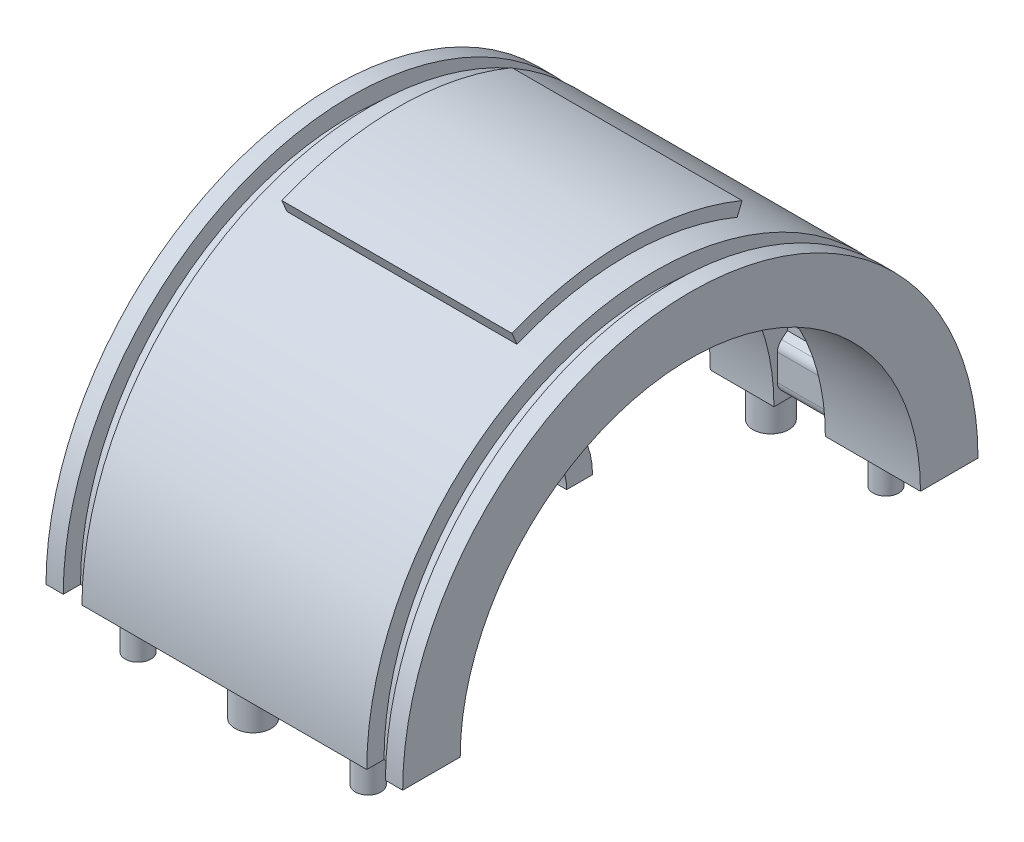
from build123d import *

# Parameters (mm, degrees)
REVOLVE1_ANGLE       = 180
BOSS_EXTRUDE1_DEPTH  = 31
CUT_EXTRUDE1_DEPTH   = 100
CIRPATTERN1_COUNT    = 6
SKETCH5_R            = 3.1275
SKETCH5_R_2          = 2.2275
BOSS_EXTRUDE2_DEPTH  = 7.155
CUT_EXTRUDE2_DEPTH   = 4.46775
MIRROR3_COPY_1_DEPTH = 4.46775
CHAMFER1_SIZE        = 2.5
FILLET1_R            = 2
FILLET2_R            = 2
SKETCH9_W            = 40
SKETCH9_H            = 2.250900446
REVOLVE2_ANGLE       = 45


with BuildPart() as part:
    # Sketch1 → Revolve1 (revolve)
    with BuildSketch(Plane(origin=(0, 0, 0), x_dir=(1, 0, 0), z_dir=(0, 1, 0))):
        with BuildLine():
            Line((24.75, 47), (28, 47))
            Line((28, 47), (28, 50))
            Line((28, 50), (31, 50))
            Line((31, 50), (31, 40))
            Line((31, 40), (-26, 40))
            add(Edge.make_bspline(
                [(-26, 40), (-27.013739482, 36.809226409), (-29.345099443, 27.828113636), (-24.523456801, 15.394699457), (-15.526264119, 14.868541835), (-9.946885113, 14)],
                knots=[0, 0, 0, 0, 0.285238859, 0.456571244, 0.779817638, 0.779817638, 0.779817638, 0.779817638], degree=3))
            Line((-9.946885113, 14), (-10, 9.5))
            add(Edge.make_bspline(
                [(-31, 40), (-32.939614555, 37.540591148), (-36.933922801, 27.582274875), (-30.082407751, 11.775662378), (-17.92187093, 9.5), (-10, 9.5)],
                knots=[0, 0, 0, 0, 0.268184782, 0.444494999, 0.822560414, 0.822560414, 0.822560414, 0.822560414], degree=3))
            Line((-31, 40), (-31, 50))
            Line((-31, 50), (-28, 50))
            Line((-28, 50), (-28, 47))
            Line((-28, 47), (-24.75, 47))
            Line((-24.75, 47), (-24.75, 50))
            Line((-24.75, 50), (24.75, 50))
            Line((24.75, 50), (24.75, 47))
        make_face()
    revolve(axis=Axis((0, 0, 0), (1, 0, 0)), revolution_arc=REVOLVE1_ANGLE)

    # Sketch6 → Boss-Extrude1 (add)
    with BuildSketch(Plane(origin=(0, 0, 0), x_dir=(0, 0, -1), z_dir=(1, 0, 0))):
        with BuildLine():
            Line((-14, 0), (-9.5, 0))
            ThreePointArc((-9.5, 0), (0, 9.5), (9.5, 0))
            Line((9.5, 0), (14, 0))
            ThreePointArc((14, 0), (0, 14), (-14, 0))
        make_face()
    extrude(amount=-BOSS_EXTRUDE1_DEPTH)

    # Sketch7 → Cut-Extrude1 (cut)
    with BuildSketch(Plane(origin=(31, 0, 0), x_dir=(0, 0, -1), z_dir=(1, 0, 0))):
        with BuildLine():
            Line((4.788282007, 13.155696691), (13.680805733, 37.587704831))
            ThreePointArc((13.680805733, 37.587704831), (0, 40), (-13.680805733, 37.587704831))
            Line((-13.680805733, 37.587704831), (-4.788282007, 13.155696691))
            ThreePointArc((-4.788282007, 13.155696691), (0, 14), (4.788282007, 13.155696691))
        make_face()
    cut_extrude1 = extrude(amount=-CUT_EXTRUDE1_DEPTH, mode=Mode.SUBTRACT)

    # CirPattern1: Cut-Extrude1 ×6 about axis
    cirpattern1_axis = Axis((0, 0, 0), (1, 0, 0))
    for i in range(1, CIRPATTERN1_COUNT):
        add(cut_extrude1.rotate(cirpattern1_axis, i * 360 / CIRPATTERN1_COUNT), mode=Mode.SUBTRACT)

    # Sketch5 → Boss-Extrude2 (add)
    with BuildSketch(Plane(origin=(0, 0, 0), x_dir=(-1, 0, 0), z_dir=(0, -1, 0))):
        with Locations((0, -45)):
            Circle(SKETCH5_R)
        with Locations((-20, -45)):
            Circle(SKETCH5_R_2)
        with Locations((20, -45)):
            Circle(SKETCH5_R_2)
    boss_extrude2 = extrude(amount=BOSS_EXTRUDE2_DEPTH)

    # Mirror1: Boss-Extrude2 across plane
    add(boss_extrude2.mirror(Plane.XY))

    # Sketch8 → Cut-Extrude2 (cut, symmetric)
    with BuildSketch(Plane(origin=(10, 0, 0), x_dir=(0, 0, -1), z_dir=(1, 0, 0))):
        Polygon((40.6105, 8.855), (42.331, 10.298670915), (42.331, 13.684170915), (40, 15.316354687), (35.522209467, 18.389470752), (35.522209467, 0), (40, 0), (40.6105, 0), align=None)
    cut_extrude2 = extrude(amount=CUT_EXTRUDE2_DEPTH, both=True, mode=Mode.SUBTRACT)

    # Mirror2: Cut-Extrude2 across plane
    add(cut_extrude2.mirror(Plane(origin=(0, 0, 0), x_dir=(0, 0, 1), z_dir=(1, 0, 0))), mode=Mode.SUBTRACT)

    # Mirror3: Cut-Extrude2 across plane
    add(cut_extrude2.mirror(Plane.XY), mode=Mode.SUBTRACT)

    # Mirror3 copy 1 sketch → Mirror3 copy 1 (cut, symmetric)
    with BuildSketch(Plane.ZY.offset(10)):
        Polygon((40.6105, 8.855), (42.331, 10.298670915), (42.331, 13.684170915), (40, 15.316354687), (35.522209467, 18.389470752), (35.522209467, 0), (40, 0), (40.6105, 0), align=None)
    extrude(amount=MIRROR3_COPY_1_DEPTH, both=True, mode=Mode.SUBTRACT)

    # Chamfer1
    chamfer1_edges = [part.edges().sort_by_distance(p)[0] for p in [
        (10, 0, -40.6105),
        (-10, 0, -40.6105),
        (10, 0, 40.6105),
        (-10, 0, 40.6105),
    ]]
    chamfer(chamfer1_edges, length=CHAMFER1_SIZE)

    # Fillet1
    fillet1_edges = [part.edges().sort_by_distance(p)[0] for p in [
        (10, 2.5, -40.6105),
        (-10, 2.5, -40.6105),
        (-10, 2.5, 40.6105),
        (10, 2.5, 40.6105),
    ]]
    fillet(fillet1_edges, radius=FILLET1_R)

    # Fillet2
    fillet2_edges = [part.edges().sort_by_distance(p)[0] for p in [
        (10, 8.855, -40.6105),
        (-10, 8.855, -40.6105),
        (10, 8.855, 40.6105),
        (-10, 8.855, 40.6105),
    ]]
    fillet(fillet2_edges, radius=FILLET2_R)

    # Sketch9 → Revolve2 (revolve, symmetric)
    with BuildSketch(Plane.XY) as revolve2_sk:
        with Locations((0, 51.125450223)):
            Rectangle(SKETCH9_W, SKETCH9_H)
    revolve(axis=Axis((43.526739174, 0, 0), (-1, 0, 0)), revolution_arc=REVOLVE2_ANGLE / 2)
    revolve(revolve2_sk.sketch, axis=Axis((43.526739174, 0, 0), (1, 0, 0)), revolution_arc=REVOLVE2_ANGLE / 2)


solid = part.part
